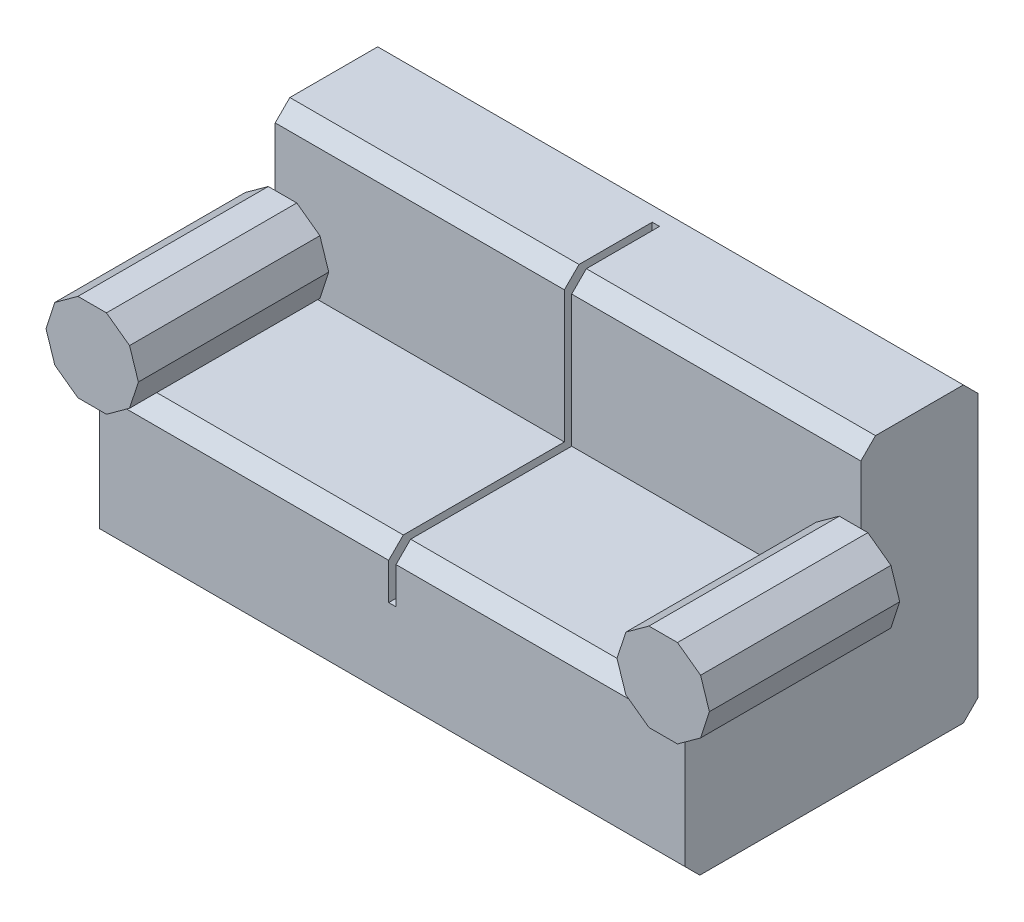
from build123d import *

# Parameters (mm, degrees)
BOSS_EXTRUDE1_DEPTH = 100
BOSS_EXTRUDE3_DEPTH = 65
SKETCH5_W           = 2.5
SKETCH5_H           = 50
CUT_EXTRUDE1_DEPTH  = 10
SKETCH6_W           = 2.5
SKETCH6_H           = 90
CUT_EXTRUDE3_DEPTH  = 5
SKETCH7_W           = 2.5
SKETCH7_H           = 70
CUT_EXTRUDE4_DEPTH  = 10
SKETCH8_W           = 2.5
SKETCH8_H           = 17.5
CUT_EXTRUDE5_DEPTH  = 5


with BuildPart() as part:
    # Sketch1 → Boss-Extrude1 (new body, symmetric)
    with BuildSketch(Plane(origin=(0, 0, 0), x_dir=(0, 0, -1), z_dir=(1, 0, 0))):
        Polygon((0, 0), (-55, 0), (-60, -5), (-60, -45), (-55, -50), (35, -50), (40, -45), (40, 45), (35, 50), (5, 50), (0, 45), align=None)
    extrude(amount=BOSS_EXTRUDE1_DEPTH, both=True)

    # Sketch2 → Boss-Extrude3 (add)
    with BuildSketch(Plane.XY):
        Polygon((113.271933364, 10), (110.259762125, 19.270509831), (102.373795443, 25), (92.626204557, 25), (84.740237875, 19.270509831), (81.728066636, 10), (84.740237875, 0.729490169), (92.626204557, -5), (102.373795443, -5), (110.259762125, 0.729490169), align=None)
    boss_extrude3 = extrude(amount=BOSS_EXTRUDE3_DEPTH)

    # Mirror1: Boss-Extrude3 across plane
    add(boss_extrude3.mirror(Plane(origin=(0, 0, 0), x_dir=(0, 0, 1), z_dir=(1, 0, 0))))

    # Sketch5 → Cut-Extrude1 (cut)
    with BuildSketch(Plane.XY):
        with Locations((0, 25)):
            Rectangle(SKETCH5_W, SKETCH5_H)
    extrude(amount=-CUT_EXTRUDE1_DEPTH, mode=Mode.SUBTRACT)

    # Sketch6 → Cut-Extrude3 (cut)
    with BuildSketch(Plane(origin=(0, 50, 0), x_dir=(1, 0, 0), z_dir=(0, 1, 0))):
        with Locations((0, -15)):
            Rectangle(SKETCH6_W, SKETCH6_H)
    extrude(amount=-CUT_EXTRUDE3_DEPTH, mode=Mode.SUBTRACT)

    # Sketch7 → Cut-Extrude4 (cut)
    with BuildSketch(Plane(origin=(0, 0, 0), x_dir=(1, 0, 0), z_dir=(0, 1, 0))):
        with Locations((0, -25)):
            Rectangle(SKETCH7_W, SKETCH7_H)
    extrude(amount=-CUT_EXTRUDE4_DEPTH, mode=Mode.SUBTRACT)

    # Sketch8 → Cut-Extrude5 (cut)
    with BuildSketch(Plane.XY.offset(60)):
        with Locations((0, -8.75)):
            Rectangle(SKETCH8_W, SKETCH8_H)
    extrude(amount=-CUT_EXTRUDE5_DEPTH, mode=Mode.SUBTRACT)


solid = part.part
